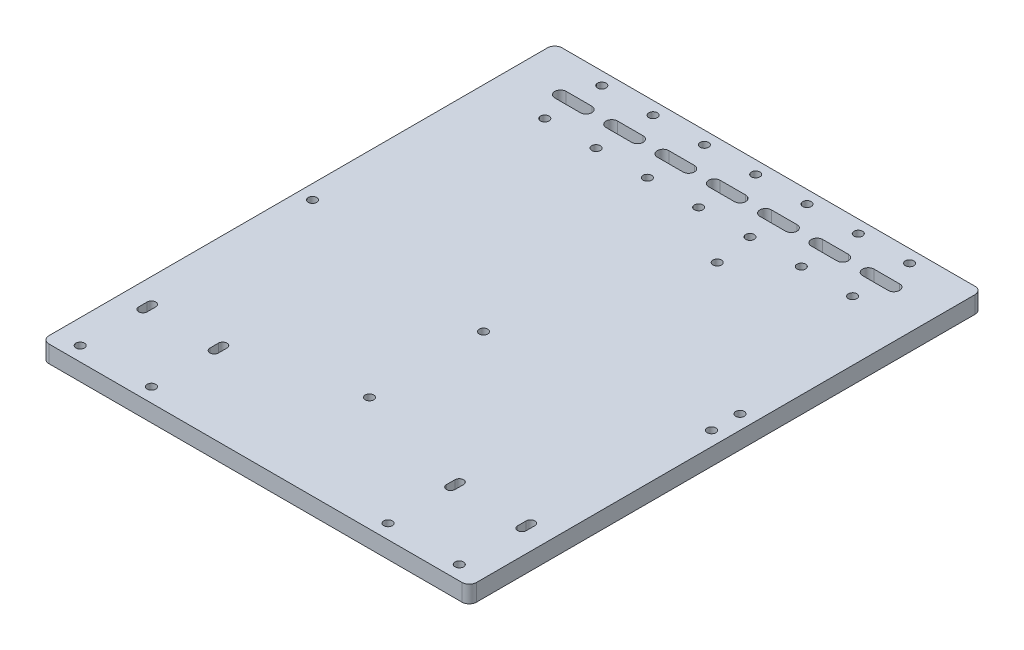
from build123d import *

# Parameters (mm, degrees)
SKETCH1_R           = 1.5
BOSS_EXTRUDE1_DEPTH = 6


with BuildPart() as part:
    # Sketch1 → Boss-Extrude1 (new body)
    with BuildSketch(Plane(origin=(0, 0, 0), x_dir=(1, 0, 0), z_dir=(0, 1, 0))):
        with BuildLine():
            Line((2.54, 0), (147.46, 0))
            ThreePointArc((147.46, 0), (149.256051224, 0.743948776), (150, 2.54))
            Line((150, 2.54), (150, 177.46))
            ThreePointArc((150, 177.46), (149.256051224, 179.256051224), (147.46, 180))
            Line((147.46, 180), (2.54, 180))
            ThreePointArc((2.54, 180), (0.743948776, 179.256051224), (0, 177.46))
            Line((0, 177.46), (0, 2.54))
            ThreePointArc((0, 2.54), (0.743948776, 0.743948776), (2.54, 0))
        make_face()
        with Locations((33.500605467, 5)):
            Circle(SKETCH1_R, mode=Mode.SUBTRACT)
        with Locations((8.500605467, 5)):
            Circle(SKETCH1_R, mode=Mode.SUBTRACT)
        with Locations((141.499394533, 5)):
            Circle(SKETCH1_R, mode=Mode.SUBTRACT)
        with Locations((116.499394533, 5)):
            Circle(SKETCH1_R, mode=Mode.SUBTRACT)
        with Locations((75, 155.5)):
            Circle(SKETCH1_R, mode=Mode.SUBTRACT)
        with Locations((39, 155.5)):
            Circle(SKETCH1_R, mode=Mode.SUBTRACT)
        with Locations((21, 155.5)):
            Circle(SKETCH1_R, mode=Mode.SUBTRACT)
        with Locations((57, 155.5)):
            Circle(SKETCH1_R, mode=Mode.SUBTRACT)
        with Locations((93, 155.5)):
            Circle(SKETCH1_R, mode=Mode.SUBTRACT)
        with Locations((111, 155.5)):
            Circle(SKETCH1_R, mode=Mode.SUBTRACT)
        with Locations((129, 155.5)):
            Circle(SKETCH1_R, mode=Mode.SUBTRACT)
        with Locations((129, 175.5)):
            Circle(SKETCH1_R, mode=Mode.SUBTRACT)
        with Locations((111, 175.5)):
            Circle(SKETCH1_R, mode=Mode.SUBTRACT)
        with Locations((93, 175.5)):
            Circle(SKETCH1_R, mode=Mode.SUBTRACT)
        with Locations((75, 175.5)):
            Circle(SKETCH1_R, mode=Mode.SUBTRACT)
        with Locations((57, 175.5)):
            Circle(SKETCH1_R, mode=Mode.SUBTRACT)
        with Locations((39, 175.5)):
            Circle(SKETCH1_R, mode=Mode.SUBTRACT)
        with Locations((21, 175.5)):
            Circle(SKETCH1_R, mode=Mode.SUBTRACT)
        with Locations((145, 100)):
            Circle(SKETCH1_R, mode=Mode.SUBTRACT)
        with Locations((95, 142)):
            Circle(SKETCH1_R, mode=Mode.SUBTRACT)
        with Locations((145, 90)):
            Circle(SKETCH1_R, mode=Mode.SUBTRACT)
        with Locations((5, 90)):
            Circle(SKETCH1_R, mode=Mode.SUBTRACT)
        with Locations((75, 80)):
            Circle(SKETCH1_R, mode=Mode.SUBTRACT)
        with Locations((75, 40)):
            Circle(SKETCH1_R, mode=Mode.SUBTRACT)
        with BuildLine():
            Line((133.5, 167.5), (124.5, 167.5))
            ThreePointArc((124.5, 167.5), (122.5, 165.5), (124.5, 163.5))
            Line((124.5, 163.5), (133.5, 163.5))
            ThreePointArc((133.5, 163.5), (135.5, 165.5), (133.5, 167.5))
        make_face(mode=Mode.SUBTRACT)
        with BuildLine():
            Line((16.5, 167.5), (25.5, 167.5))
            ThreePointArc((25.5, 167.5), (27.5, 165.5), (25.5, 163.5))
            Line((25.5, 163.5), (16.5, 163.5))
            ThreePointArc((16.5, 163.5), (14.5, 165.5), (16.5, 167.5))
        make_face(mode=Mode.SUBTRACT)
        with BuildLine():
            Line((34.5, 167.5), (43.5, 167.5))
            ThreePointArc((43.5, 167.5), (45.5, 165.5), (43.5, 163.5))
            Line((43.5, 163.5), (34.5, 163.5))
            ThreePointArc((34.5, 163.5), (32.5, 165.5), (34.5, 167.5))
        make_face(mode=Mode.SUBTRACT)
        with BuildLine():
            Line((52.5, 167.5), (61.5, 167.5))
            ThreePointArc((61.5, 167.5), (63.5, 165.5), (61.5, 163.5))
            Line((61.5, 163.5), (52.5, 163.5))
            ThreePointArc((52.5, 163.5), (50.5, 165.5), (52.5, 167.5))
        make_face(mode=Mode.SUBTRACT)
        with BuildLine():
            Line((70.5, 167.5), (79.5, 167.5))
            ThreePointArc((79.5, 167.5), (81.5, 165.5), (79.5, 163.5))
            Line((79.5, 163.5), (70.5, 163.5))
            ThreePointArc((70.5, 163.5), (68.5, 165.5), (70.5, 167.5))
        make_face(mode=Mode.SUBTRACT)
        with BuildLine():
            Line((115.5, 167.5), (106.5, 167.5))
            ThreePointArc((106.5, 167.5), (104.5, 165.5), (106.5, 163.5))
            Line((106.5, 163.5), (115.5, 163.5))
            ThreePointArc((115.5, 163.5), (117.5, 165.5), (115.5, 167.5))
        make_face(mode=Mode.SUBTRACT)
        with BuildLine():
            Line((97.5, 167.5), (88.5, 167.5))
            ThreePointArc((88.5, 167.5), (86.5, 165.5), (88.5, 163.5))
            Line((88.5, 163.5), (97.5, 163.5))
            ThreePointArc((97.5, 163.5), (99.5, 165.5), (97.5, 167.5))
        make_face(mode=Mode.SUBTRACT)
        with BuildLine():
            Line((10.000605467, 30), (10.000605467, 27))
            ThreePointArc((10.000605467, 27), (8.500605467, 25.5), (7.000605467, 27))
            Line((7.000605467, 27), (7.000605467, 30))
            ThreePointArc((7.000605467, 30), (8.500605467, 31.5), (10.000605467, 30))
        make_face(mode=Mode.SUBTRACT)
        with BuildLine():
            Line((35.000605467, 30), (35.000605467, 27))
            ThreePointArc((35.000605467, 27), (33.500605467, 25.5), (32.000605467, 27))
            Line((32.000605467, 27), (32.000605467, 30))
            ThreePointArc((32.000605467, 30), (33.500605467, 31.5), (35.000605467, 30))
        make_face(mode=Mode.SUBTRACT)
        with BuildLine():
            Line((114.999394533, 30), (114.999394533, 27))
            ThreePointArc((114.999394533, 27), (116.499394533, 25.5), (117.999394533, 27))
            Line((117.999394533, 27), (117.999394533, 30))
            ThreePointArc((117.999394533, 30), (116.499394533, 31.5), (114.999394533, 30))
        make_face(mode=Mode.SUBTRACT)
        with BuildLine():
            Line((139.999394533, 30), (139.999394533, 27))
            ThreePointArc((139.999394533, 27), (141.499394533, 25.5), (142.999394533, 27))
            Line((142.999394533, 27), (142.999394533, 30))
            ThreePointArc((142.999394533, 30), (141.499394533, 31.5), (139.999394533, 30))
        make_face(mode=Mode.SUBTRACT)
    extrude(amount=BOSS_EXTRUDE1_DEPTH)


solid = part.part
